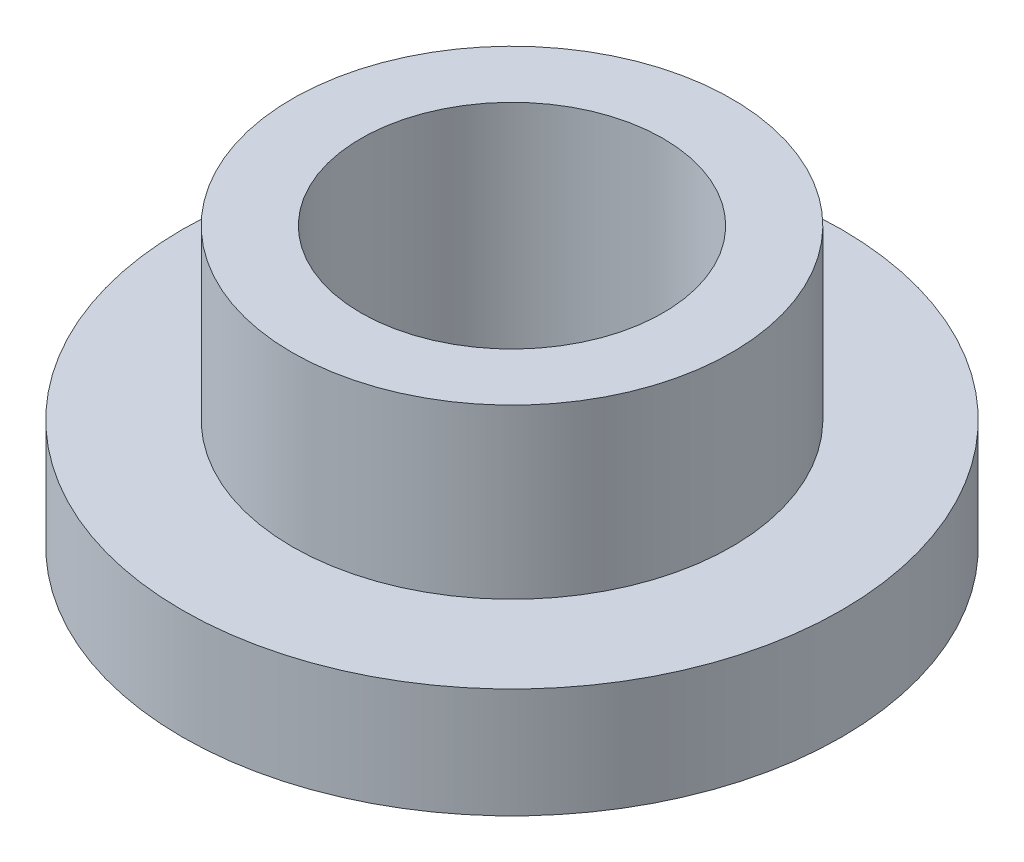
from build123d import *

# Parameters (mm, degrees)
SKETCH1_R           = 4.7625
SKETCH1_R_2         = 2.1828125
BOSS_EXTRUDE1_DEPTH = 1.5875
SKETCH2_R           = 3.175
SKETCH2_R_2         = 2.1828125
BOSS_EXTRUDE2_DEPTH = 2.428875


with BuildPart() as part:
    # Sketch1 → Boss-Extrude1 (new body)
    with BuildSketch(Plane(origin=(0, 0, 0), x_dir=(1, 0, 0), z_dir=(0, 1, 0))):
        Circle(SKETCH1_R)
        Circle(SKETCH1_R_2, mode=Mode.SUBTRACT)
    extrude(amount=BOSS_EXTRUDE1_DEPTH)

    # Sketch2 → Boss-Extrude2 (add)
    with BuildSketch(Plane(origin=(0, 1.5875, 0), x_dir=(1, 0, 0), z_dir=(0, 1, 0))):
        Circle(SKETCH2_R)
        Circle(SKETCH2_R_2, mode=Mode.SUBTRACT)
    extrude(amount=BOSS_EXTRUDE2_DEPTH)


solid = part.part
